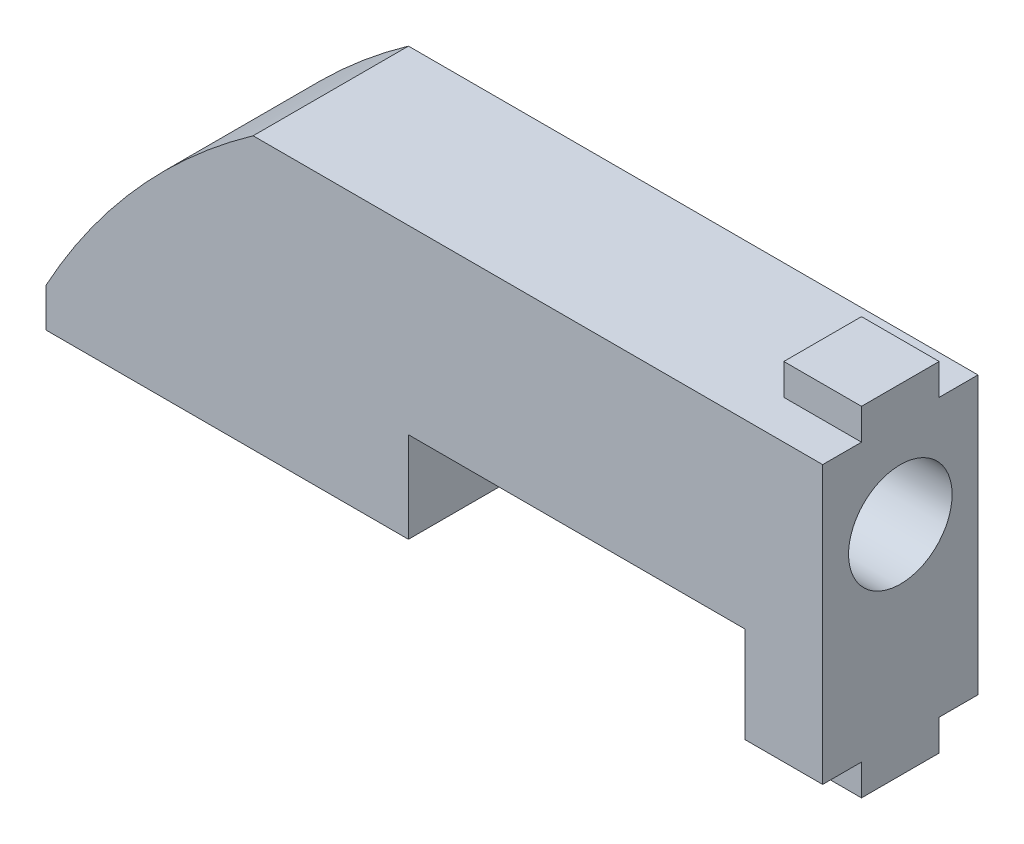
from build123d import *

# Parameters (mm, degrees)
EXTRUSION1_DEPTH                  = 3
ESQUISSE2_W                       = 3
ESQUISSE2_H                       = 3
EXTRUSION2_DEPTH                  = 1.2
ESQUISSE3_W                       = 3
ESQUISSE3_H                       = 3
EXTRUSION3_DEPTH                  = 1.2
DIAM_TRE_DU_PER_AGE_4_0_4_1_D     = 4
DIAM_TRE_DU_PER_AGE_4_0_4_1_DEPTH = 3
DIAM_TRE_DU_PER_AGE_4_0_4_1_TIP   = 1.201721238


with BuildPart() as part:
    # Esquisse1 → Extrusion1 (new body, symmetric)
    with BuildSketch(Plane.XY):
        with BuildLine():
            Line((0, 0), (0, 1.5))
            ThreePointArc((0, 1.5), (3.484063784, 6.45860997), (8, 10.5))
            Line((8, 10.5), (30, 10.5))
            Line((30, 10.5), (30, -0.2))
            Line((30, -0.2), (27, -0.2))
            Line((27, -0.2), (27, 3.5))
            Line((27, 3.5), (14, 3.5))
            Line((14, 3.5), (14, 0))
            Line((14, 0), (0, 0))
        make_face()
    extrude(amount=EXTRUSION1_DEPTH, both=True)

    # Esquisse2 → Extrusion2 (add)
    with BuildSketch(Plane(origin=(0, 10.5, 0), x_dir=(1, 0, 0), z_dir=(0, 1, 0))):
        with Locations((28.5, 0)):
            Rectangle(ESQUISSE2_W, ESQUISSE2_H)
    extrude(amount=EXTRUSION2_DEPTH)

    # Esquisse3 → Extrusion3 (add)
    with BuildSketch(Plane.XZ.offset(0.2)):
        with Locations((28.5, 0)):
            Rectangle(ESQUISSE3_W, ESQUISSE3_H)
    extrude(amount=EXTRUSION3_DEPTH)

    # Diamètre du perçage Ø4.0 (4)1
    with Locations(Plane(origin=(30, 0, 0), x_dir=(0, 0, -1), z_dir=(1, 0, 0))):
        with Locations((0, 7)):
            Hole(DIAM_TRE_DU_PER_AGE_4_0_4_1_D / 2, depth=DIAM_TRE_DU_PER_AGE_4_0_4_1_DEPTH)
            with Locations((0, 0, -(DIAM_TRE_DU_PER_AGE_4_0_4_1_DEPTH + DIAM_TRE_DU_PER_AGE_4_0_4_1_TIP / 2))):  # 118° drill point
                Cone(0, DIAM_TRE_DU_PER_AGE_4_0_4_1_D / 2, DIAM_TRE_DU_PER_AGE_4_0_4_1_TIP, mode=Mode.SUBTRACT)


solid = part.part
